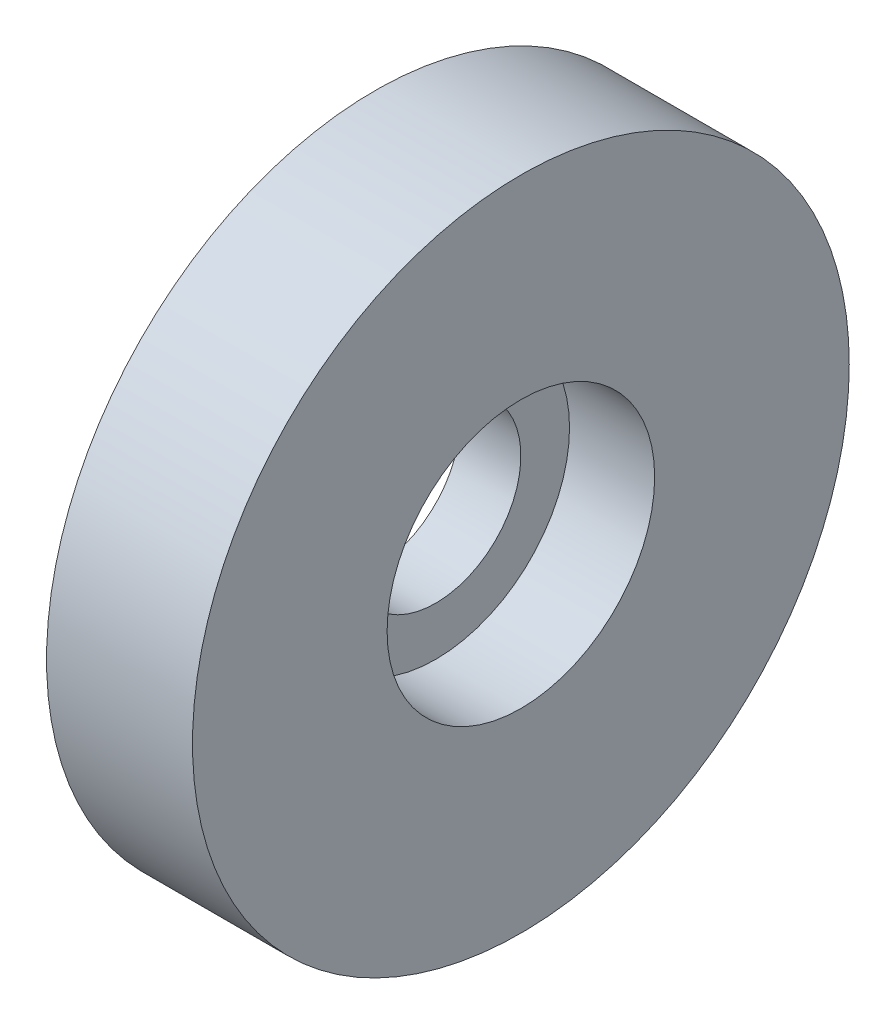
from build123d import *

# Parameters (mm, degrees)
SKETCH2_R          = 2.5
CUT_EXTRUDE1_DEPTH = 47.445475819
CIRPATTERN1_COUNT  = 10


with BuildPart() as part:
    # Sketch1 → Revolve1 (revolve)
    with BuildSketch(Plane.XY, mode=Mode.PRIVATE) as revolve1_sk:
        Polygon((-5, 0), (5, 0), (5, -4), (12, -4), (16.497946055, -15.125128372), (13, -20), (-13, -20), (-16.497946055, -15.125128372), (-12, -4), (-5, -4), align=None)
    revolve(revolve1_sk.sketch.rotate(Axis((0, 7, 0), (1, 0, 0)), 270), axis=Axis((0, 7, 0), (1, 0, 0)))

    # SurfaceCut1
    split(bisect_by=Plane(origin=(0, 0, 0), x_dir=(0, 0, -1), z_dir=(1, 0, 0)), keep=Keep.TOP)

    # SurfaceCut4
    split(bisect_by=Plane(origin=(12, 0, 0), x_dir=(0, 0, -1), z_dir=(1, 0, 0)), keep=Keep.BOTTOM)

    # Sketch2 → Cut-Extrude1 (cut, through all)
    with BuildSketch(Plane(origin=(16.497946055, 0, 0), x_dir=(0, 0, -1), z_dir=(1, 0, 0))):
        with Locations((0, 25.5)):
            Circle(SKETCH2_R)
        with Locations((6, 27.5)):
            Circle(SKETCH2_R)
    extrude(amount=-CUT_EXTRUDE1_DEPTH, mode=Mode.SUBTRACT)

    # CirPattern1: part ×10 about axis
    cirpattern1_axis = Axis((0, 7, 0), (1, 0, 0))


with BuildPart() as part_1:
    add(part.part)
    for i in range(1, CIRPATTERN1_COUNT):
        add(part.part.rotate(cirpattern1_axis, i * 360 / CIRPATTERN1_COUNT))


solid = part_1.part
